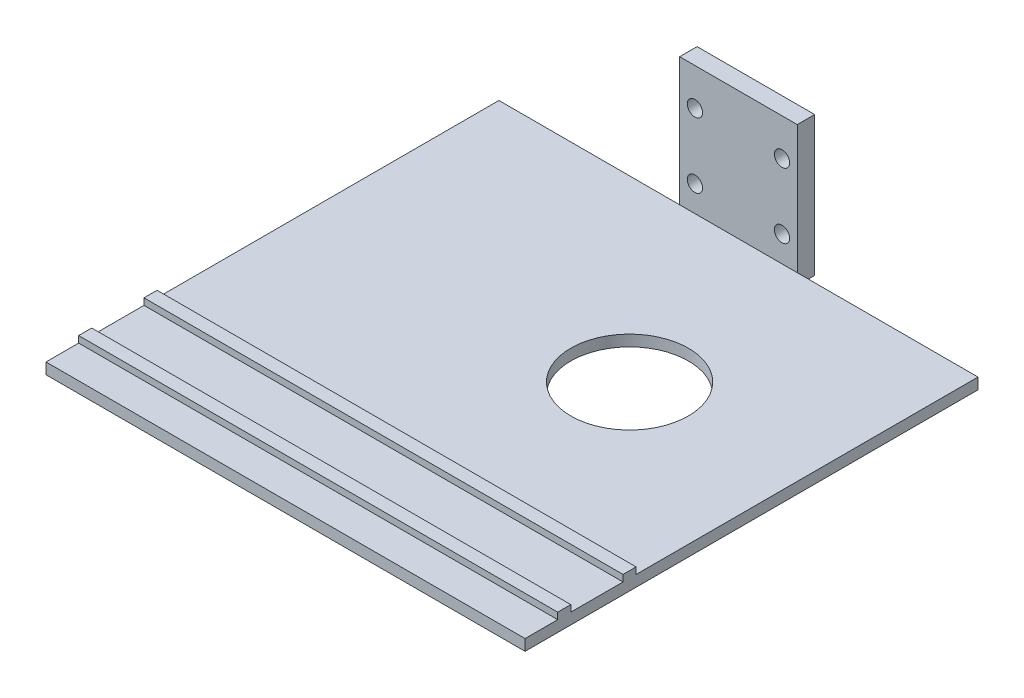
from build123d import *

# Parameters (mm, degrees)
SCHIZZO1_W                        = 27
SCHIZZO1_H                        = 36
ESTRUSIONE_ESTRUSIONE1_DEPTH      = 4
SCHIZZO10_R                       = 1.75
TAGLIO_ESTRUSIONE5_DEPTH          = 10
SCHIZZO12_W                       = 104
SCHIZZO12_H                       = 2.549259356
ESTRUSIONE_ESTRUSIONE2_DEPTH      = 55
ESTRUSIONE_ESTRUSIONE2_DEPTH_BACK = 55
SCHIZZO14_W                       = 3
SCHIZZO14_H                       = 1.5
ESTRUSIONE_ESTRUSIONE3_DEPTH      = 110
SCHIZZO15_W                       = 27
SCHIZZO15_H                       = 4
TAGLIO_ESTRUSIONE6_DEPTH          = 5
SCHIZZO16_R                       = 13.5
TAGLIO_ESTRUSIONE7_DEPTH          = 10


with BuildPart() as part:
    # Schizzo1 → Estrusione-Estrusione1 (new body)
    with BuildSketch(Plane.XY):
        with Locations((13.5, -18)):
            Rectangle(SCHIZZO1_W, SCHIZZO1_H)
    extrude(amount=ESTRUSIONE_ESTRUSIONE1_DEPTH)

    # Schizzo10 → Taglio-Estrusione5 (cut)
    with BuildSketch(Plane.XY.offset(4)):
        with Locations((3.5, -12.5)):
            Circle(SCHIZZO10_R)
        with Locations((23.5, -12.5)):
            Circle(SCHIZZO10_R)
        with Locations((23.5, -27.5)):
            Circle(SCHIZZO10_R)
        with Locations((3.5, -27.5)):
            Circle(SCHIZZO10_R)
    extrude(amount=-TAGLIO_ESTRUSIONE5_DEPTH, mode=Mode.SUBTRACT)

    # Schizzo12 → Estrusione-Estrusione2 (add, two sides)
    with BuildSketch(Plane(origin=(13.5, 0, 0), x_dir=(0, 0, -1), z_dir=(1, 0, 0))) as estrusione_estrusione2_sk:
        with Locations((-56, -34.725370322)):
            Rectangle(SCHIZZO12_W, SCHIZZO12_H)
    extrude(amount=ESTRUSIONE_ESTRUSIONE2_DEPTH)
    extrude(estrusione_estrusione2_sk.sketch, amount=-ESTRUSIONE_ESTRUSIONE2_DEPTH_BACK)

    # Schizzo14 → Estrusione-Estrusione3 (add)
    with BuildSketch(Plane.ZY.offset(41.5)):
        with Locations((84, -32.700740644)):
            Rectangle(SCHIZZO14_W, SCHIZZO14_H)
        with Locations((99, -32.700740644)):
            Rectangle(SCHIZZO14_W, SCHIZZO14_H)
    extrude(amount=-ESTRUSIONE_ESTRUSIONE3_DEPTH)

    # Schizzo15 → Taglio-Estrusione6 (cut, through all)
    with BuildSketch(Plane.XY.offset(4)):
        with Locations((13.5, -2)):
            Rectangle(SCHIZZO15_W, SCHIZZO15_H)
    extrude(amount=-TAGLIO_ESTRUSIONE6_DEPTH, mode=Mode.SUBTRACT)

    # Schizzo16 → Taglio-Estrusione7 (cut)
    with BuildSketch(Plane(origin=(0, -33.450740644, 0), x_dir=(1, 0, 0), z_dir=(0, 1, 0))):
        with Locations((29.5, -45)):
            Circle(SCHIZZO16_R)
    extrude(amount=-TAGLIO_ESTRUSIONE7_DEPTH, mode=Mode.SUBTRACT)


solid = part.part
